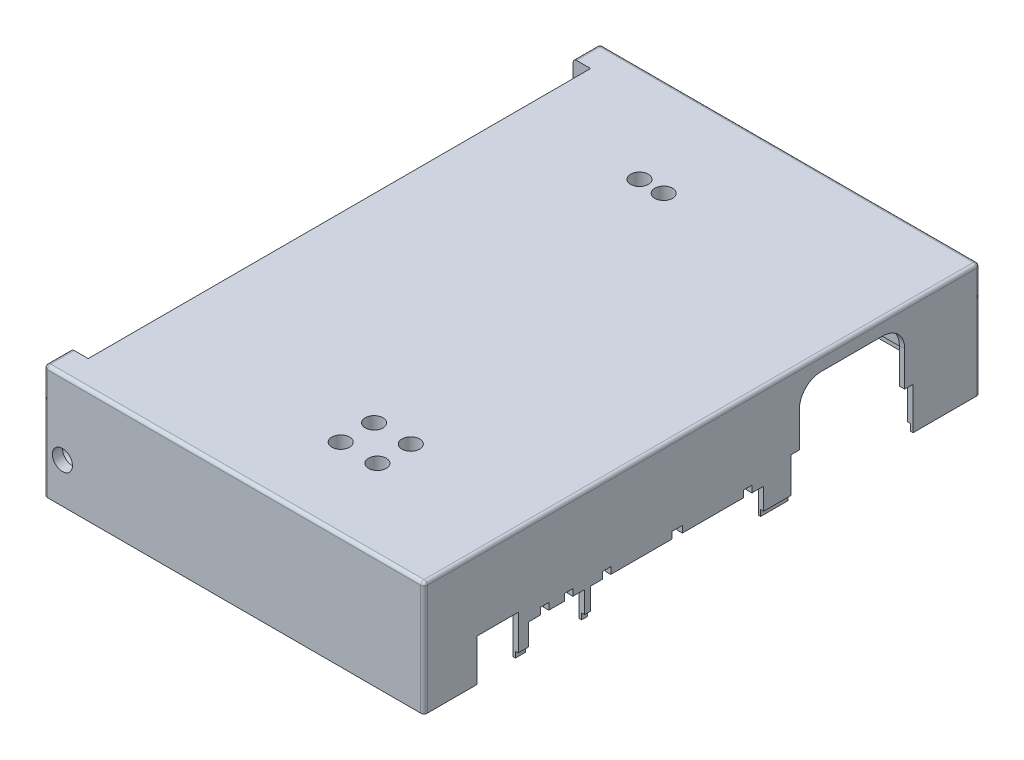
from build123d import *

# Parameters (mm, degrees)
EXTRUDE_2_DEPTH           = 35
SKETCH_3_W                = 9.6
SKETCH_3_H                = 9.6
EXTRUDE_3_DEPTH           = 35
SKETCH_8_W                = 10
SKETCH_8_H                = 6.4
EXTRUDE_4_DEPTH           = 35
EXTRUDE_5_DEPTH           = 2
FILLET_1_R                = 2
SKETCH_11_R               = 1.45
CUT_EXTRUDE_7_DEPTH       = 8
CUT_EXTRUDE_17_DEPTH      = 1.6
SKETCH_77_W               = 0.9
SKETCH_77_H               = 3.100006964
SKETCH_77_H_2             = 1.824993516
SKETCH_77_H_3             = 8.175815104
EXTRUDE_15_DEPTH          = 2
SKETCH_78_W               = 0.9
SKETCH_78_H               = 1.824993516
SKETCH_78_H_2             = 8.175815104
SKETCH_78_H_3             = 3.100006964
CUT_EXTRUDE_20_DEPTH      = 2
SKETCH_79_W               = 3.100006964
SKETCH_79_H               = 0.2
SKETCH_79_W_2             = 1.824993516
SKETCH_79_W_3             = 8.175815104
CUT_EXTRUDE_21_DEPTH      = 0.7
CUT_EXTRUDE_18_DEPTH      = 4.5
SKETCH_32_W               = 113.6
SKETCH_32_H               = 166.2
EXTRUDE_6_DEPTH           = 1.6
SKETCH_33_W               = 7
SKETCH_33_H               = 150.2
CUT_EXTRUDE_19_DEPTH      = 1.6
SKETCH_35_R               = 3.65
EXTRUDE_7_DEPTH           = 5
HOLE_WIZARD_3_D           = 5.3
HOLE_WIZARD_3_CSINK_D     = 6.3
HOLE_WIZARD_3_CSINK_ANGLE = 90
SKETCH_48_R               = 3.65
EXTRUDE_8_DEPTH           = 5
SKETCH_53_R               = 3.65
EXTRUDE_9_DEPTH           = 5
SKETCH_59_R               = 3.65
EXTRUDE_12_DEPTH          = 5
SKETCH_64_R               = 3.65
EXTRUDE_13_DEPTH          = 5
SKETCH_72_R               = 3.65
EXTRUDE_14_DEPTH          = 5
HOLE_WIZARD_5_D           = 5.3
HOLE_WIZARD_5_CSINK_D     = 6.3
HOLE_WIZARD_5_CSINK_ANGLE = 90
FILLET_2_R                = 1
SKETCH_81_W               = 10
SKETCH_81_H               = 163
EXTRUDE_16_DEPTH          = 6


with BuildPart() as part:
    # Эскиз2 → Бобышка-Вытянуть2 (new body)
    with BuildSketch(Plane.XZ):
        Polygon((-54.2, 83.1), (54.2, 83.1), (54.2, -83.1), (-54.2, -83.1), (-59.4, -83.1), (-59.4, -81.5), (-54.2, -81.5), (52.6, -81.5), (52.6, 81.5), (-54.2, 81.5), (-59.4, 81.5), (-59.4, 83.1), align=None)
    extrude(amount=EXTRUDE_2_DEPTH)

    # Эскиз3 → Бобышка-Вытянуть3 (add)
    with BuildSketch(Plane.XZ):
        with Locations((47.8, 76.7)):
            Rectangle(SKETCH_3_W, SKETCH_3_H)
        with Locations((47.8, -76.7)):
            Rectangle(SKETCH_3_W, SKETCH_3_H)
    extrude(amount=EXTRUDE_3_DEPTH)

    # Эскиз8 → Бобышка-Вытянуть4 (add)
    with BuildSketch(Plane.XZ):
        with Locations((-54.4, 78.3)):
            Rectangle(SKETCH_8_W, SKETCH_8_H)
    extrude_4 = extrude(amount=EXTRUDE_4_DEPTH)

    # Зеркальное отражение1: Бобышка-Вытянуть4 across plane
    add(extrude_4.mirror(Plane.XY))

    # Эскиз10 → Бобышка-Вытянуть5 (add)
    with BuildSketch(Plane.XZ.offset(35)):
        Polygon((-59.4, 83.1), (-59.4, 75.1), (-58.7, 75.1), (-58.7, 82.4), (53.5, 82.4), (53.5, -82.4), (-58.7, -82.4), (-58.7, -75.1), (-59.4, -75.1), (-59.4, -83.1), (54.2, -83.1), (54.2, 83.1), align=None)
    extrude(amount=EXTRUDE_5_DEPTH)

    # Эскиз69 → Отверстие2 (revolve, cut)
    with BuildSketch(Plane(origin=(-53.9, -25, -83.1), x_dir=(0, 1, 0), z_dir=(1, 0, 0))):
        Polygon((0, 0), (0, 9), (1.55, 9), (1.55, 4.45), (3, 3), (3, 0), align=None)
    hole_wizard_2 = revolve(axis=Axis((-53.9, -25, -89.230023899), (0, 0, 1)), mode=Mode.SUBTRACT)

    # Зеркальное отражение2: Отверстие2 across plane
    add(hole_wizard_2.mirror(Plane.XY), mode=Mode.SUBTRACT)

    # Скругление1
    fillet_1_edges = [part.edges().sort_by_distance(p)[0] for p in [
        (43, -17.5, 71.9),
        (43, -17.5, -71.9),
    ]]
    fillet(fillet_1_edges, radius=FILLET_1_R)

    # Эскиз11 → Вырез-Вытянуть7 (cut)
    with BuildSketch(Plane.XZ.offset(35)):
        with Locations((47.8, 76.7)):
            Circle(SKETCH_11_R)
        with Locations((47.8, -76.7)):
            Circle(SKETCH_11_R)
    extrude(amount=-CUT_EXTRUDE_7_DEPTH, mode=Mode.SUBTRACT)

    # Эскиз24 → Вырез-Вытянуть17 (cut)
    with BuildSketch(Plane(origin=(54.2, 0, 0), x_dir=(0, 0, -1), z_dir=(1, 0, 0))):
        Polygon((-67.115753945, -24.45856124), (-54.915753678, -24.45856124), (-54.900002552, -24.45856124), (-54.900002552, -37), (-54.950002552, -37), (-67.200003552, -37), (-67.200003552, -24.45856124), align=None)
        with BuildLine():
            Line((26.600813792, -24.458561201), (26.600813792, -37))
            Line((26.600813792, -37), (63.100006082, -37))
            Line((63.100006082, -37), (63.100006082, -24.458561201))
            Line((63.100006082, -24.458561201), (60.600006082, -24.458561201))
            Line((60.600006082, -24.458561201), (60.600006082, -13.958561201))
            ThreePointArc((60.600006082, -13.958561201), (58.686114673, -9.338018606), (54.065572078, -7.424127197))
            Line((54.065572078, -7.424127197), (35.635247795, -7.424127197))
            ThreePointArc((35.635247795, -7.424127197), (31.0147052, -9.338018606), (29.100813792, -13.958561201))
            Line((29.100813792, -13.958561201), (29.100813792, -24.458561201))
            Line((29.100813792, -24.458561201), (26.600813792, -24.458561201))
        make_face()
        Polygon((-33.275002252, -37), (18.424998688, -37), (18.424998688, -28.5), (14.924998688, -28.5), (14.924998688, -26.5), (12.424998688, -26.5), (12.424998688, -28.5), (-5.875001312, -28.5), (-5.875001312, -26.5), (-8.975002252, -26.5), (-8.975002252, -28.5), (-27.275002252, -28.5), (-27.275002252, -26.5), (-29.775002252, -26.5), (-29.775002252, -28.5), (-33.275002252, -28.5), align=None)
        Polygon((-51.799995588, -37), (-35.099995768, -37), (-35.099995768, -28.5), (-38.601386518, -28.5), (-38.601386518, -26.5), (-41.101386518, -26.5), (-41.101386518, -28.5), (-45.799995588, -28.5), (-45.799995588, -26.5), (-48.299995588, -26.5), (-48.299995588, -28.5), (-51.799995588, -28.5), align=None)
    extrude(amount=-CUT_EXTRUDE_17_DEPTH, mode=Mode.SUBTRACT)

    # Эскиз77 → Бобышка-Вытянуть15 (add)
    with BuildSketch(Plane.XZ.offset(35)):
        with Locations((53.05, 53.34999907)):
            Rectangle(SKETCH_77_W, SKETCH_77_H)
        with Locations((53.05, 34.18749901)):
            Rectangle(SKETCH_77_W, SKETCH_77_H_2)
        with Locations((53.05, -22.51290624)):
            Rectangle(SKETCH_77_W, SKETCH_77_H_3)
    extrude(amount=EXTRUDE_15_DEPTH)

    # Эскиз78 → Вырез-Вытянуть20 (cut)
    with BuildSketch(Plane.XZ.offset(37)):
        with Locations((53.75, 34.18749901)):
            Rectangle(SKETCH_78_W, SKETCH_78_H)
        with Locations((53.75, -22.51290624)):
            Rectangle(SKETCH_78_W, SKETCH_78_H_2)
        with Locations((53.75, 53.34999907)):
            Rectangle(SKETCH_78_W, SKETCH_78_H_3)
    extrude(amount=-CUT_EXTRUDE_20_DEPTH, mode=Mode.SUBTRACT)

    # Эскиз79 → Вырез-Вытянуть21 (cut)
    with BuildSketch(Plane(origin=(53.3, 0, 0), x_dir=(0, 0, -1), z_dir=(1, 0, 0))):
        with Locations((-53.34999907, -36.9)):
            Rectangle(SKETCH_79_W, SKETCH_79_H)
        with Locations((-34.18749901, -36.9)):
            Rectangle(SKETCH_79_W_2, SKETCH_79_H)
        with Locations((22.51290624, -36.9)):
            Rectangle(SKETCH_79_W_3, SKETCH_79_H)
    extrude(amount=-CUT_EXTRUDE_21_DEPTH, mode=Mode.SUBTRACT)

    # Эскиз1 → Вырез-Вытянуть18 (cut)
    with BuildSketch(Plane(origin=(0, 0, 0), x_dir=(1, 0, 0), z_dir=(0, 1, 0))):
        Polygon((-54.2, 83.1), (-61.2, 83.1), (-61.2, -83.1), (-54.2, -83.1), (54.2, -83.1), (54.2, 83.1), align=None)
    extrude(amount=-CUT_EXTRUDE_18_DEPTH, mode=Mode.SUBTRACT)

    # Эскиз32 → Бобышка-Вытянуть6 (add)
    with BuildSketch(Plane(origin=(0, -4.5, 0), x_dir=(1, 0, 0), z_dir=(0, 1, 0))):
        with Locations((-2.6, 0)):
            Rectangle(SKETCH_32_W, SKETCH_32_H)
    extrude(amount=EXTRUDE_6_DEPTH)

    # Эскиз33 → Вырез-Вытянуть19 (cut)
    with BuildSketch(Plane(origin=(0, -2.9, 0), x_dir=(1, 0, 0), z_dir=(0, 1, 0))):
        with Locations((-57.7, 0)):
            Rectangle(SKETCH_33_W, SKETCH_33_H)
    extrude(amount=-CUT_EXTRUDE_19_DEPTH, mode=Mode.SUBTRACT)

    # Эскиз35 → Бобышка-Вытянуть7 (add)
    with BuildSketch(Plane.XZ.offset(4.5)):
        with Locations((5.169259644, 49.00012207)):
            Circle(SKETCH_35_R)
    extrude(amount=EXTRUDE_7_DEPTH)

    # Отверстие3 (through all)
    with Locations(Plane(origin=(0, -9.5, 0), x_dir=(-1, 0, 0), z_dir=(0, -1, 0))):
        with Locations((-5.169259644, -49.00012207)):
            CounterSinkHole(HOLE_WIZARD_3_D / 2, HOLE_WIZARD_3_CSINK_D / 2, counter_sink_angle=HOLE_WIZARD_3_CSINK_ANGLE)

    # Эскиз48 → Бобышка-Вытянуть8 (add)
    with BuildSketch(Plane.XZ.offset(4.5)):
        with Locations((-18.21427002, -53.725112916)):
            Circle(SKETCH_48_R)
    extrude(amount=EXTRUDE_8_DEPTH)

    # Эскиз53 → Бобышка-Вытянуть9 (add)
    with BuildSketch(Plane.XZ.offset(4.5)):
        with Locations((16.144265744, 49.00012207)):
            Circle(SKETCH_53_R)
    extrude(amount=EXTRUDE_9_DEPTH)

    # Эскиз59 → Бобышка-Вытянуть12 (add)
    with BuildSketch(Plane.XZ.offset(4.5)):
        with Locations((-10.9749991, -53.725112916)):
            Circle(SKETCH_59_R)
    extrude(amount=EXTRUDE_12_DEPTH)

    # Эскиз64 → Бобышка-Вытянуть13 (add)
    with BuildSketch(Plane.XZ.offset(4.5)):
        with Locations((5.172398423, 58.982823693)):
            Circle(SKETCH_64_R)
    extrude(amount=EXTRUDE_13_DEPTH)

    # Эскиз72 → Бобышка-Вытянуть14 (add)
    with BuildSketch(Plane.XZ.offset(4.5)):
        with Locations((16.144265744, 58.982823693)):
            Circle(SKETCH_72_R)
    extrude(amount=EXTRUDE_14_DEPTH)

    # Отверстие5 (through all)
    with Locations(Plane(origin=(0, -9.5, 0), x_dir=(-1, 0, 0), z_dir=(0, -1, 0))):
        with Locations((-16.144265744, -58.982823693), (-16.144265744, -49.00012207), (-5.172398423, -58.982823693), (10.9749991, 53.725112916), (18.21427002, 53.725112916)):
            CounterSinkHole(HOLE_WIZARD_5_D / 2, HOLE_WIZARD_5_CSINK_D / 2, counter_sink_angle=HOLE_WIZARD_5_CSINK_ANGLE)

    # Скругление2
    fillet_2_edges = [part.edges().sort_by_distance(p)[0] for p in [
        (54.2, -19.95, 83.1),
        (54.2, -19.95, -83.1),
        (-59.4, -19.95, -83.1),
        (-59.4, -19.95, 83.1),
        (-2.6, -2.9, 83.1),
        (54.2, -2.9, 0),
        (-2.6, -2.9, -83.1),
        (-59.4, -2.9, -79.1),
        (-59.4, -2.9, 79.1),
    ]]
    fillet(fillet_2_edges, radius=FILLET_2_R)

    # Эскиз81 → Бобышка-Вытянуть16 (add)
    with BuildSketch(Plane.XZ.offset(4.5)):
        with Locations((27.6, 0)):
            Rectangle(SKETCH_81_W, SKETCH_81_H)
        with Locations((-44.4, 0)):
            Rectangle(SKETCH_81_W, SKETCH_81_H)
    extrude(amount=EXTRUDE_16_DEPTH)


solid = part.part
